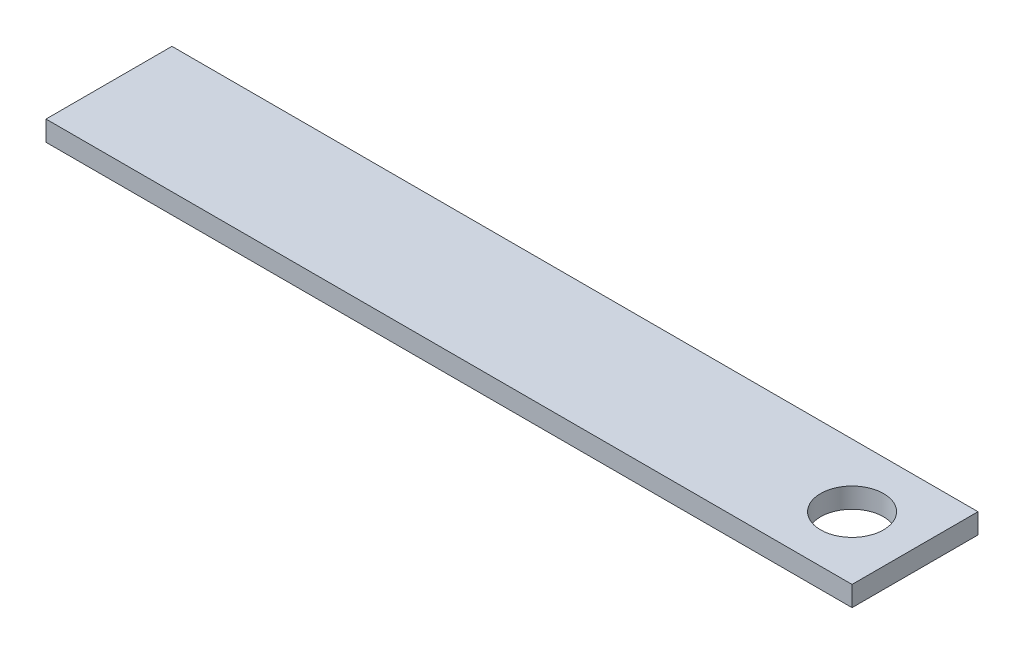
from build123d import *

# Parameters (mm, degrees)
SKETCH1_W           = 160
SKETCH1_H           = 25
SKETCH1_R           = 6.25
BOSS_EXTRUDE1_DEPTH = 4


with BuildPart() as part:
    # Sketch1 → Boss-Extrude1 (new body)
    with BuildSketch(Plane(origin=(0, 0, 0), x_dir=(1, 0, 0), z_dir=(0, 1, 0))):
        Rectangle(SKETCH1_W, SKETCH1_H)
        with Locations((67.5, 0)):
            Circle(SKETCH1_R, mode=Mode.SUBTRACT)
    extrude(amount=BOSS_EXTRUDE1_DEPTH)


solid = part.part
